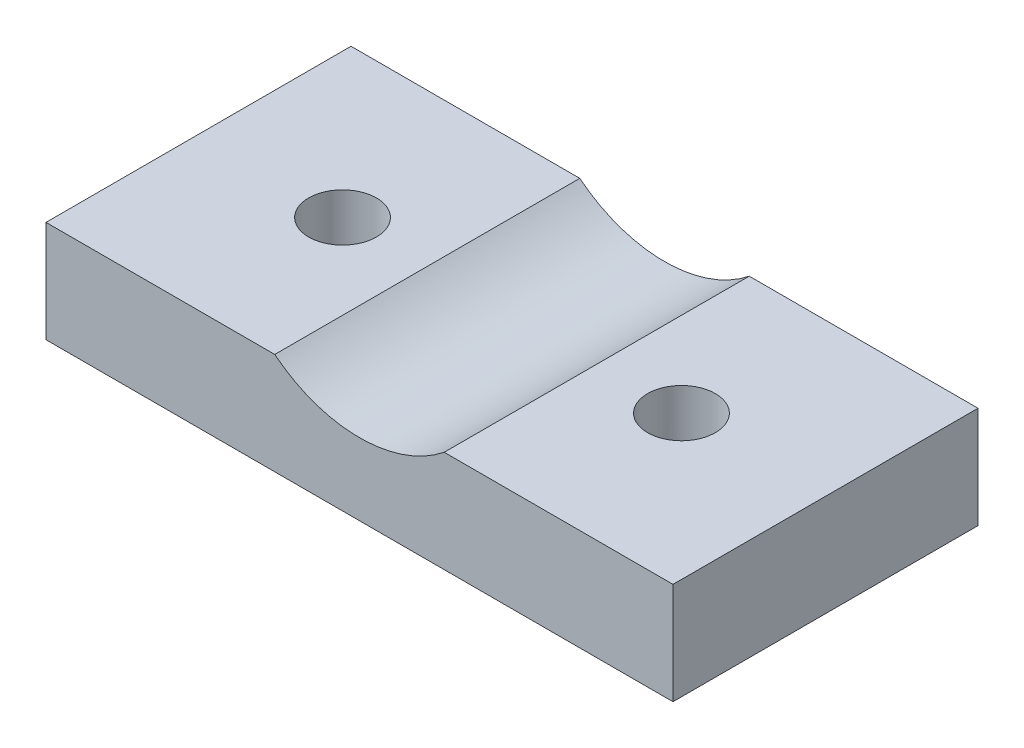
from build123d import *

# Parameters (mm, degrees)
BOSS_EXTRUDE1_DEPTH = 36
SKETCH2_R           = 4
CUT_EXTRUDE1_DEPTH  = 7
SKETCH3_R           = 4
CUT_EXTRUDE2_DEPTH  = 7


with BuildPart() as part:
    # Sketch1 → Boss-Extrude1 (new body)
    with BuildSketch(Plane.XY):
        with BuildLine():
            Line((10, 6), (37, 6))
            Line((37, 6), (37, -6))
            Line((37, -6), (-37, -6))
            Line((-37, -6), (-37, 6))
            Line((-37, 6), (-10, 6))
            ThreePointArc((-10, 6), (0, 2.489995997), (10, 6))
        make_face()
    extrude(amount=-BOSS_EXTRUDE1_DEPTH)

    # Sketch2 → Cut-Extrude1 (cut, through all)
    with BuildSketch(Plane(origin=(0, 0, 0), x_dir=(1, 0, 0), z_dir=(0, 1, 0))):
        with Locations((-20, 18)):
            Circle(SKETCH2_R)
        with Locations((20, 18)):
            Circle(SKETCH2_R)
    extrude(amount=CUT_EXTRUDE1_DEPTH, mode=Mode.SUBTRACT)

    # Sketch3 → Cut-Extrude2 (cut, through all)
    with BuildSketch(Plane(origin=(0, 0, 0), x_dir=(1, 0, 0), z_dir=(0, 1, 0))):
        with Locations((-20, 18)):
            Circle(SKETCH3_R)
        with Locations((20, 18)):
            Circle(SKETCH3_R)
    extrude(amount=-CUT_EXTRUDE2_DEPTH, mode=Mode.SUBTRACT)


solid = part.part
